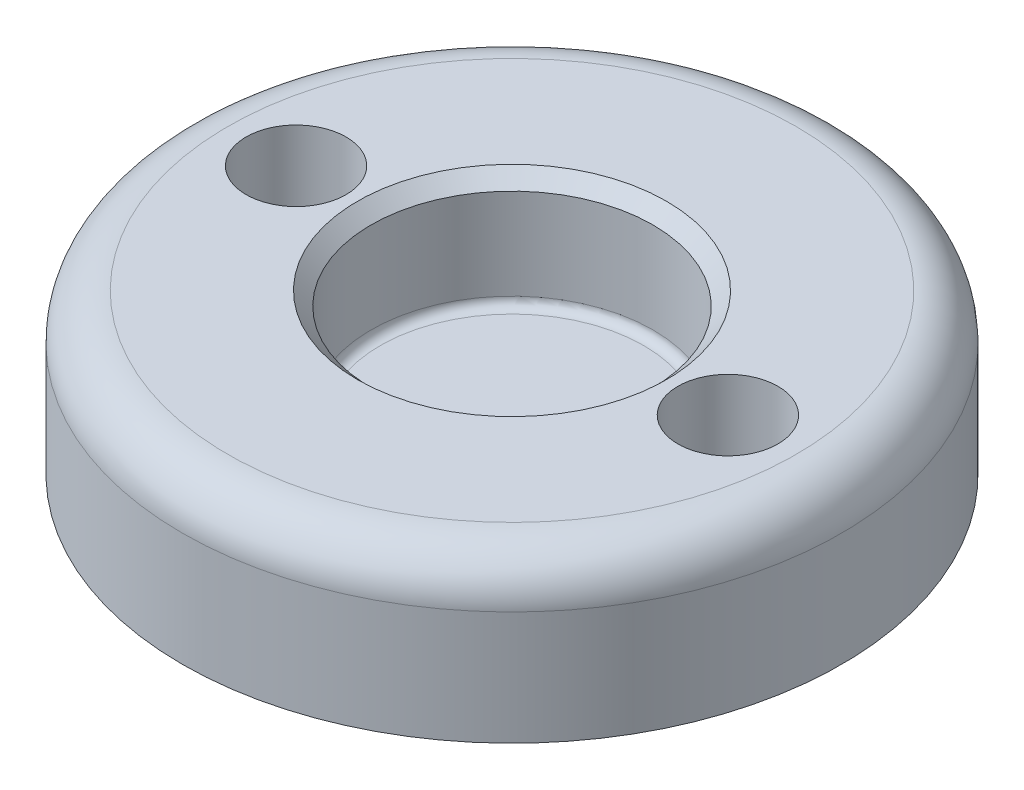
from build123d import *

# Parameters (mm, degrees)
CHAMFER2_SIZE     = 0.3
CIRPATTERN1_COUNT = 2
FILLET2_R         = 0.2
FILLET3_R         = 1


with BuildPart() as part:
    # Sketch1 → Revolve1 (revolve)
    with BuildSketch(Plane.XY, mode=Mode.PRIVATE) as revolve1_sk:
        Polygon((0, 0), (-7.25, 0), (-7.25, 3.5), (-3.1, 3.5), (-3.1, 1), (0, 1), align=None)
    revolve(revolve1_sk.sketch.rotate(Axis((0, 0, 0), (0, 1, 0)), 270), axis=Axis((0, 0, 0), (0, 1, 0)))

    # Chamfer2
    chamfer2_edges = [part.edges().sort_by_distance(p)[0] for p in [
        (0, 3.5, 3.1),
    ]]
    chamfer(chamfer2_edges, length=CHAMFER2_SIZE)

    # Sketch4 → CSK for M2 Flat Head Machine Screw1 (revolve, cut)
    with BuildSketch(Plane(origin=(-4.75, 0, 0), x_dir=(0, 0, -1), z_dir=(1, 0, 0))):
        Polygon((0, 0), (0, 5.660946681), (1.1, 5), (1.1, 1.1), (2.2, 0), align=None)
    csk_for_m2_flat_head_machine_screw1 = revolve(axis=Axis((-4.75, -6.35, 0), (0, 1, 0)), mode=Mode.SUBTRACT)

    # CirPattern1: CSK for M2 Flat Head Machine Screw1 ×2 about axis
    cirpattern1_axis = Axis((0, 0, 0), (0, 1, 0))
    for i in range(1, CIRPATTERN1_COUNT):
        add(csk_for_m2_flat_head_machine_screw1.rotate(cirpattern1_axis, i * 360 / CIRPATTERN1_COUNT), mode=Mode.SUBTRACT)

    # Fillet2
    fillet2_edges = [part.edges().sort_by_distance(p)[0] for p in [
        (0, 1, 3.1),
    ]]
    fillet(fillet2_edges, radius=FILLET2_R)

    # Fillet3
    fillet3_edges = [part.edges().sort_by_distance(p)[0] for p in [
        (0, 3.5, 7.25),
    ]]
    fillet(fillet3_edges, radius=FILLET3_R)


solid = part.part
